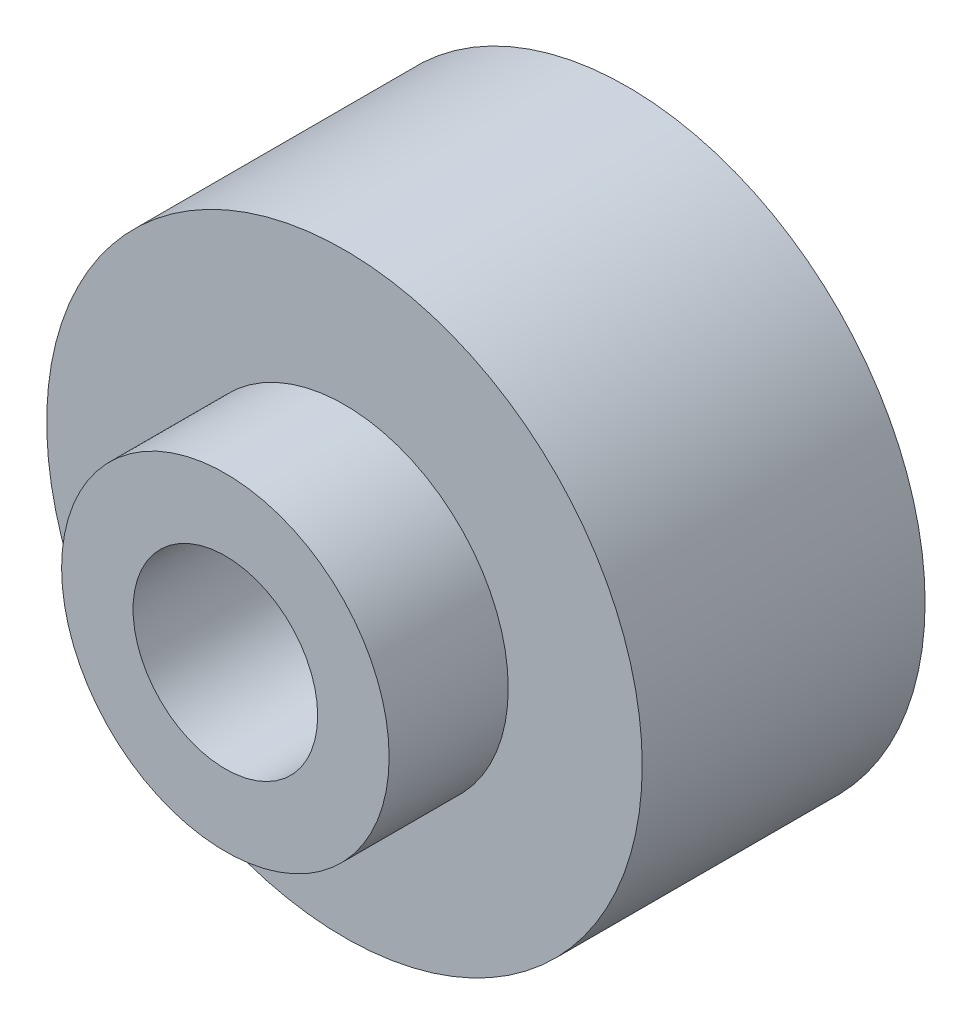
from build123d import *

# Parameters (mm, degrees)
SKETCH_1_R      = 5
SKETCH_1_R_2    = 1.55
EXTRUDE_1_DEPTH = 4.75
SKETCH_2_R      = 2.75
SKETCH_2_R_2    = 1.55
EXTRUDE_2_DEPTH = 2


with BuildPart() as part:
    # 草图1 → 凸台-拉伸1 (new body)
    with BuildSketch(Plane.XY):
        Circle(SKETCH_1_R)
        Circle(SKETCH_1_R_2, mode=Mode.SUBTRACT)
    extrude(amount=EXTRUDE_1_DEPTH)

    # 草图2 → 凸台-拉伸2 (add)
    with BuildSketch(Plane.XY.offset(4.75)):
        Circle(SKETCH_2_R)
        Circle(SKETCH_2_R_2, mode=Mode.SUBTRACT)
    extrude(amount=EXTRUDE_2_DEPTH)

    # 草图5 → 切除-旋转1 (revolve, cut)
    with BuildSketch(Plane(origin=(0, 0, 0), x_dir=(1, 0, 0), z_dir=(0, 1, 0))):
        Polygon((3, 0), (1.55, -2), (0, -2), (0, 0), align=None)
    revolve(axis=Axis((0, 0, 4.75), (0, 0, -1)), mode=Mode.SUBTRACT)


solid = part.part
